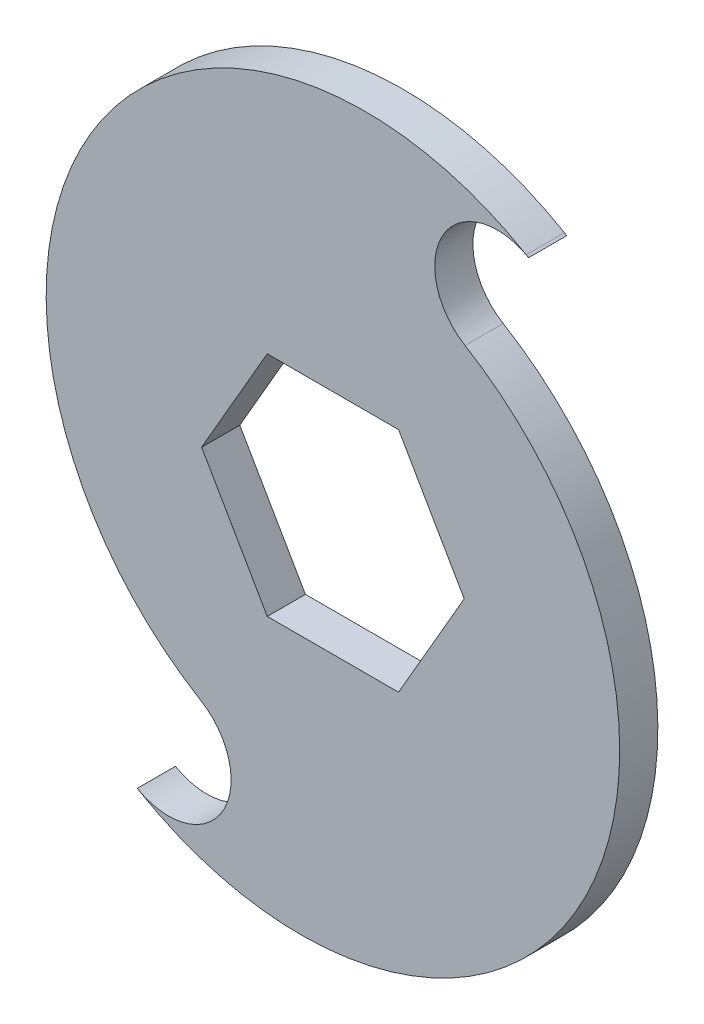
from build123d import *

# Parameters (mm, degrees)
ESBO_O1_R                = 50
RESSALTO_EXTRUS_O2_DEPTH = 5
CORTE_EXTRUS_O3_DEPTH    = 10


with BuildPart() as part:
    # Esboço1 → Ressalto-extrusão2 (new body)
    with BuildSketch(Plane.XY):
        Circle(ESBO_O1_R)
        Polygon((17.205038022, 0), (8.602519011, 14.9), (-8.602519011, 14.9), (-17.205038022, 0), (-8.602519011, -14.9), (8.602519011, -14.9), align=None, mode=Mode.SUBTRACT)
    extrude(amount=RESSALTO_EXTRUS_O2_DEPTH)

    # Esboço2 → Corte-extrusão3 (cut)
    with BuildSketch(Plane.XY.offset(5)):
        with BuildLine():
            ThreePointArc((17.315705324, 28.798343726), (31.728781641, -28.350948037), (-25.332809256, -43.107409748))
            ThreePointArc((-25.332809256, -43.107409748), (24.833037845, -43.397237601), (50, 0))
            ThreePointArc((50, 0), (43.485034201, 24.678974868), (25.637927978, 42.926642647))
            ThreePointArc((25.637927978, 42.926642647), (14.476168491, 39.986199306), (17.315705324, 28.798343726))
        make_face()
        with BuildLine():
            ThreePointArc((25.332809256, 43.107409748), (-43.017296722, 25.485528889), (-25.637927978, -42.926642647))
            ThreePointArc((-25.637927978, -42.926642647), (-14.476168491, -39.986199306), (-17.315705324, -28.798343726))
            ThreePointArc((-17.315705324, -28.798343726), (-31.728781641, 28.350948037), (25.332809256, 43.107409748))
        make_face()
    extrude(amount=-CORTE_EXTRUS_O3_DEPTH, mode=Mode.SUBTRACT)


solid = part.part
